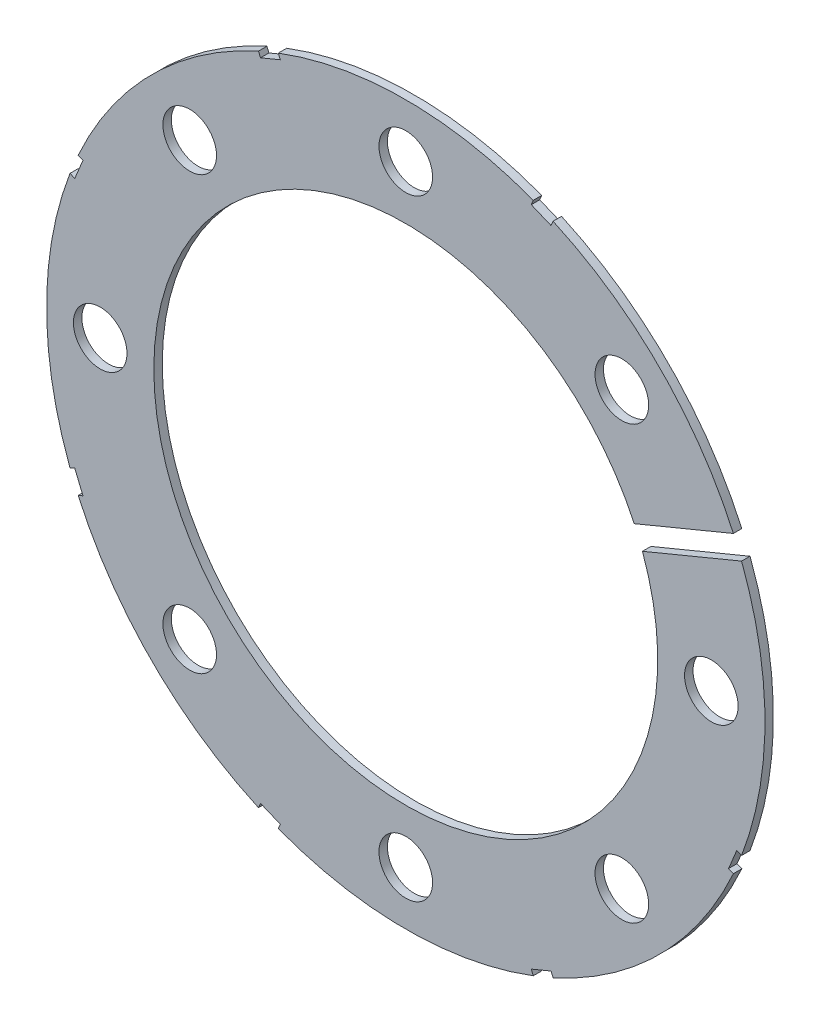
from build123d import *

# Parameters (mm, degrees)
SKETCH4_R           = 42.545
BOSS_EXTRUDE2_DEPTH = 1
SKETCH5_R           = 29.845
CUT_EXTRUDE5_DEPTH  = 2
SKETCH6_R           = 3.175
CUT_EXTRUDE6_DEPTH  = 2
CIRPATTERN1_COUNT   = 8
CUT_EXTRUDE11_DEPTH = 2


with BuildPart() as part:
    # Sketch4 → Boss-Extrude2 (new body)
    with BuildSketch(Plane.XY):
        Circle(SKETCH4_R)
    extrude(amount=BOSS_EXTRUDE2_DEPTH)

    # Sketch5 → Cut-Extrude5 (cut, through all)
    with BuildSketch(Plane.XY.offset(1)):
        Circle(SKETCH5_R)
    extrude(amount=-CUT_EXTRUDE5_DEPTH, mode=Mode.SUBTRACT)

    # Sketch6 → Cut-Extrude6 (cut, through all)
    with BuildSketch(Plane.XY.offset(1)):
        with Locations((36.195, 0)):
            Circle(SKETCH6_R)
    cut_extrude6 = extrude(amount=-CUT_EXTRUDE6_DEPTH, mode=Mode.SUBTRACT)

    # CirPattern1: Cut-Extrude6 ×8 about axis
    cirpattern1_axis = Axis((0, 0, 0), (0, 0, 1))
    for i in range(1, CIRPATTERN1_COUNT):
        add(cut_extrude6.rotate(cirpattern1_axis, i * 360 / CIRPATTERN1_COUNT), mode=Mode.SUBTRACT)

    # Sketch8 → Cut-Extrude11 (cut, through all)
    with BuildSketch(Plane.XY.offset(1)):
        Polygon((42.34042777, 18.912617514), (23.56719567, 11.136490168), (24.539211588, 8.789836155), (43.312443689, 16.565963501), align=None)
        Polygon((17.697597616, 39.407110255), (15.350943603, 40.379126173), (14.864935644, 39.205799167), (17.211589657, 38.233783248), align=None)
        Polygon((-15.350943603, 40.379126173), (-17.697597616, 39.407110255), (-17.211589657, 38.233783248), (-14.864935644, 39.205799167), align=None)
        Polygon((-39.407110255, 17.697597616), (-40.379126173, 15.350943603), (-39.205799167, 14.864935644), (-38.233783248, 17.211589657), align=None)
        Polygon((-40.379126173, -15.350943603), (-39.407110255, -17.697597616), (-38.233783248, -17.211589657), (-39.205799167, -14.864935644), align=None)
        Polygon((-17.697597616, -39.407110255), (-15.350943603, -40.379126173), (-14.864935644, -39.205799167), (-17.211589657, -38.233783248), align=None)
        Polygon((15.350943603, -40.379126173), (17.697597616, -39.407110255), (17.211589657, -38.233783248), (14.864935644, -39.205799167), align=None)
        Polygon((39.407110255, -17.697597616), (40.379126173, -15.350943603), (39.205799167, -14.864935644), (38.233783248, -17.211589657), align=None)
    extrude(amount=-CUT_EXTRUDE11_DEPTH, mode=Mode.SUBTRACT)


solid = part.part
